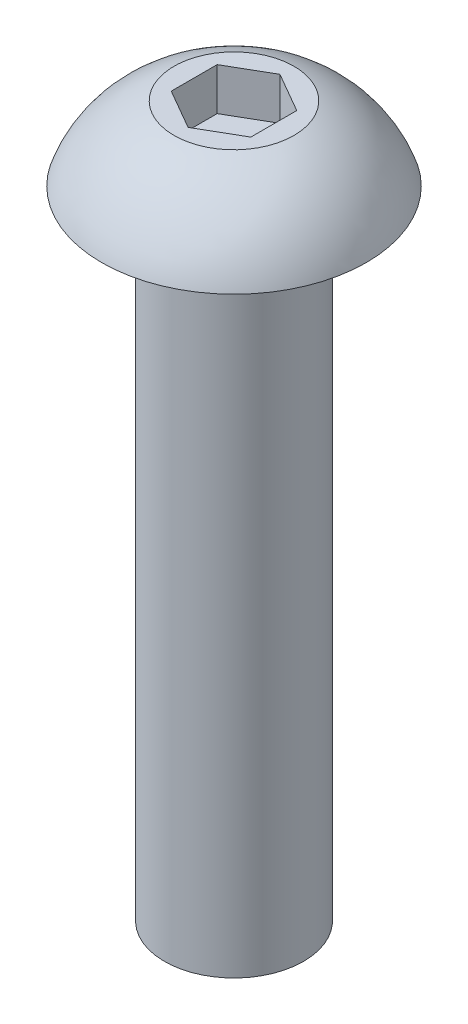
from build123d import *

# Parameters (mm, degrees)
CUT_EXTRUDE1_DEPTH = 1.27


with BuildPart() as part:
    # Sketch1 → Revolve1 (revolve)
    with BuildSketch(Plane.XY):
        with BuildLine():
            Line((-2.0828, 0), (-3.9624, 0))
            ThreePointArc((-3.9624, 0), (-3.131232795, 1.352726455), (-1.79477003, 2.2098))
            Line((-1.79477003, 2.2098), (0, 2.2098))
            Line((0, 2.2098), (0, -19.05))
            Line((0, -19.05), (-2.0828, -19.05))
            Line((-2.0828, -19.05), (-2.0828, 0))
        make_face()
    revolve(axis=Axis((0, -19.05, 0), (0, 1, 0)))

    # Sketch2 → Cut-Extrude1 (cut)
    with BuildSketch(Plane(origin=(0, 2.2098, 0), x_dir=(1, 0, 0), z_dir=(0, 1, 0))):
        Polygon((-1.190625, 0.687407664), (-1.190625, -0.687407664), (0, -1.374815329), (1.190625, -0.687407664), (1.190625, 0.687407664), (0, 1.374815329), align=None)
    extrude(amount=-CUT_EXTRUDE1_DEPTH, mode=Mode.SUBTRACT)


solid = part.part
